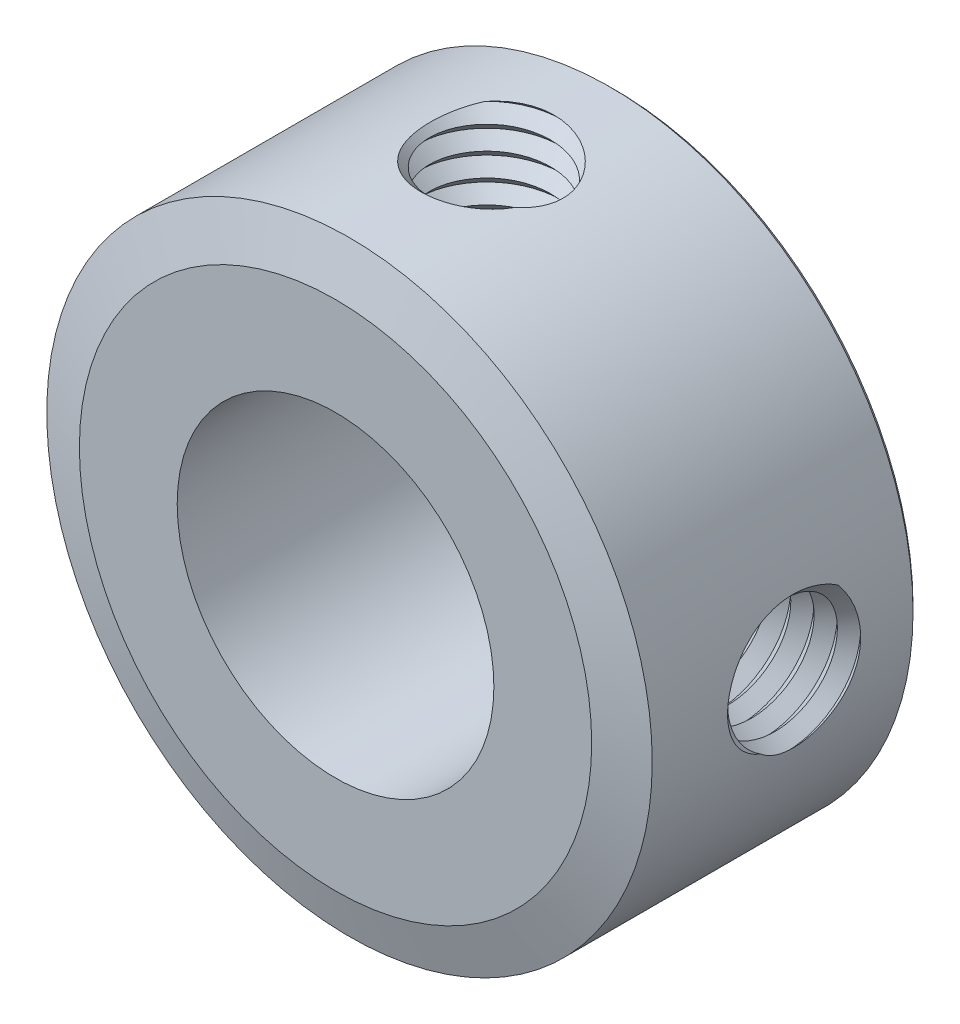
from build123d import *

# Parameters (mm, degrees)
SKETCH1_R              = 6.5
SKETCH1_R_2            = 3.4
EXTRUDE1_DEPTH         = 6
CHAMFER1_SIZE          = 0.3
CHAMFER1_SIZE2         = 1
SKETCH2_R              = 1.25
EXTRUDE2_DEPTH         = 7.5
CUT_SWEEP1_PITCH       = 0.5
CUT_SWEEP1_HEIGHT      = 8
CUT_SWEEP1_RADIUS      = 1.25
CUT_SWEEP1_START_ANGLE = -135
CIRPATTERN1_COUNT      = 2
CIRPATTERN1_ANGLE      = 270
CIRPATTERN2_COUNT      = 2
CIRPATTERN2_ANGLE      = 90
CHAMFER2_SIZE          = 0.1


with BuildPart() as part:
    # Sketch1 → Extrude1 (new body)
    with BuildSketch(Plane.XY):
        Circle(SKETCH1_R)
        Circle(SKETCH1_R_2, mode=Mode.SUBTRACT)
    extrude(amount=EXTRUDE1_DEPTH)

    # Chamfer1
    chamfer1_edges = [part.edges().sort_by_distance(p)[0] for p in [
        (-6.5, 0, 6),
    ]]
    chamfer1_side = [part.faces().sort_by_distance(p)[0] for p in [
        (-6.5, 0, 3),
    ]]
    chamfer(chamfer1_edges, length=CHAMFER1_SIZE, length2=CHAMFER1_SIZE2, reference=chamfer1_side[0])

    # Sketch2 → Extrude2 (cut, through all)
    with BuildSketch(Plane(origin=(0, 0, 0), x_dir=(1, 0, 0), z_dir=(0, 1, 0))):
        with Locations((0, -2.6)):
            Circle(SKETCH2_R)
    extrude2 = extrude(amount=EXTRUDE2_DEPTH, mode=Mode.SUBTRACT)

    # Cut-Sweep1: sweep along a helix
    with BuildLine() as cut_sweep1_path:
        add(Helix(CUT_SWEEP1_PITCH, CUT_SWEEP1_HEIGHT, CUT_SWEEP1_RADIUS, center=(0, 0, 2.6), direction=(0, 1, 0), mode=Mode.PRIVATE).rotate(Axis((0, 0, 2.6), (0, 1, 0)), CUT_SWEEP1_START_ANGLE))
    # Sketch3 → Cut-Sweep1 (sweep, cut)
    with BuildSketch(Plane.XY.offset(2.596315895)):
        Polygon((-1.301928668, 7.197169477), (-1.551928668, 6.947169477), (-1.301928668, 6.697169477), (-0.79432779, 6.697169477), (-0.79432779, 7.197169477), align=None)
    cut_sweep1 = sweep(path=cut_sweep1_path.line, is_frenet=True, mode=Mode.SUBTRACT)

    # CirPattern1: Extrude2 ×2 about axis
    cirpattern1_axis = Axis((0, 0, 6), (0, 0, 1))
    for i in range(1, CIRPATTERN1_COUNT):
        add(extrude2.rotate(cirpattern1_axis, i * CIRPATTERN1_ANGLE / (CIRPATTERN1_COUNT - 1)), mode=Mode.SUBTRACT)

    # CirPattern2: Cut-Sweep1 ×2 about axis
    cirpattern2_axis = Axis((0, 0, 6), (0, 0, -1))
    for i in range(1, CIRPATTERN2_COUNT):
        add(cut_sweep1.rotate(cirpattern2_axis, i * CIRPATTERN2_ANGLE / (CIRPATTERN2_COUNT - 1)), mode=Mode.SUBTRACT)

    # Chamfer2
    chamfer2_edges = [part.edges().sort_by_distance(p)[0] for p in [
        (-6.5, 0, 0),
        (-3.4, 0, 0),
    ]]
    chamfer(chamfer2_edges, length=CHAMFER2_SIZE)


solid = part.part
